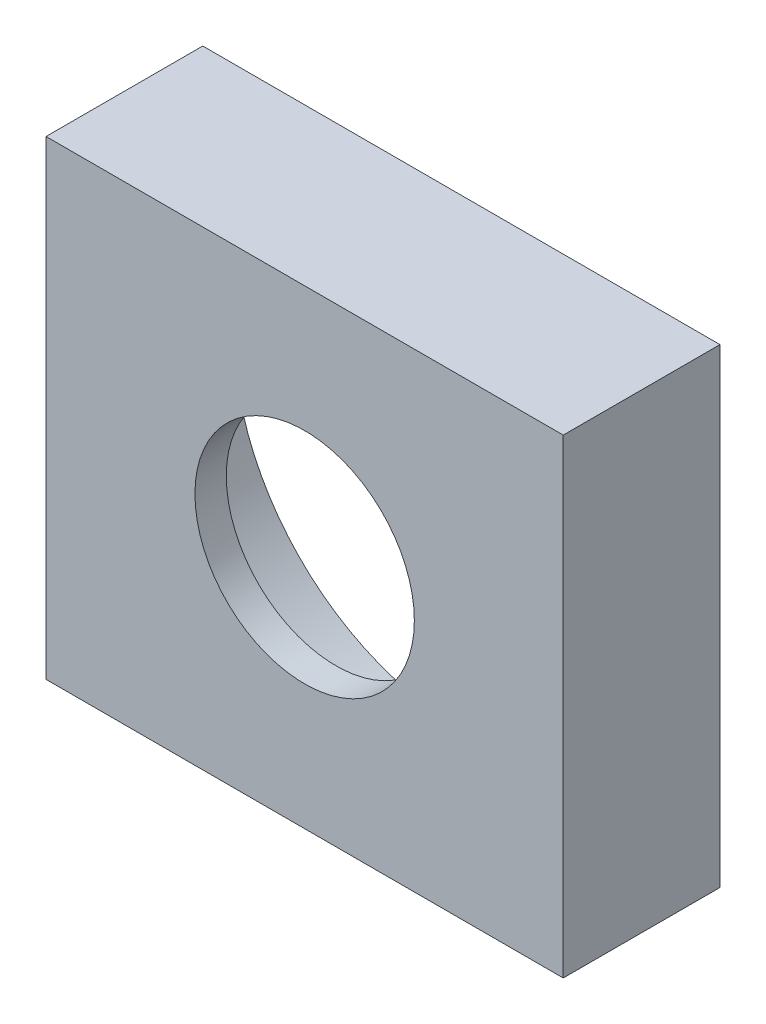
from build123d import *

# Parameters (mm, degrees)
SKETCH1_W                   = 33
SKETCH1_H                   = 30
BOSS_EXTRUDE1_DEPTH         = 10
CUT_EXTRUDE1_REACH          = 12
SKETCH2_R                   = 7
SKETCH3_R                   = 14.5
CUT_EXTRUDE2_DEPTH          = 8
TAP_DRILL_FOR_M3_TAP2_D     = 2.5
TAP_DRILL_FOR_M3_TAP2_DEPTH = 8
TAP_DRILL_FOR_M3_TAP2_TIP   = 0.751075774


with BuildPart() as part:
    # Sketch1 → Boss-Extrude1 (new body)
    with BuildSketch(Plane.XY):
        with Locations((16.5, 15)):
            Rectangle(SKETCH1_W, SKETCH1_H)
    extrude(amount=BOSS_EXTRUDE1_DEPTH)

    # Sketch2 → Cut-Extrude1 (cut, up to next)
    with BuildSketch(Plane.XY.offset(10), mode=Mode.PRIVATE) as cut_extrude1_sk1:
        with Locations((16.5, 15)):
            Circle(SKETCH2_R)
    cut_extrude1_tool1 = extrude(cut_extrude1_sk1.sketch, amount=-CUT_EXTRUDE1_REACH, mode=Mode.PRIVATE) & part.part
    add(cut_extrude1_tool1.solids().sort_by_distance((16.5, 15, 10))[0], mode=Mode.SUBTRACT)

    # Sketch3 → Cut-Extrude2 (cut)
    with BuildSketch(Plane(origin=(0, 0, 0), x_dir=(-1, 0, 0), z_dir=(0, 0, -1))):
        with Locations((-16.5, 15)):
            Circle(SKETCH3_R)
    extrude(amount=-CUT_EXTRUDE2_DEPTH, mode=Mode.SUBTRACT)

    # Tap Drill for M3 Tap2
    with Locations(Plane(origin=(0, 0, 0), x_dir=(-1, 0, 0), z_dir=(0, -1, 0))):
        with Locations((-3, -6), (-30, -6)):
            Hole(TAP_DRILL_FOR_M3_TAP2_D / 2, depth=TAP_DRILL_FOR_M3_TAP2_DEPTH)
            with Locations((0, 0, -(TAP_DRILL_FOR_M3_TAP2_DEPTH + TAP_DRILL_FOR_M3_TAP2_TIP / 2))):  # 118° drill point
                Cone(0, TAP_DRILL_FOR_M3_TAP2_D / 2, TAP_DRILL_FOR_M3_TAP2_TIP, mode=Mode.SUBTRACT)


solid = part.part
